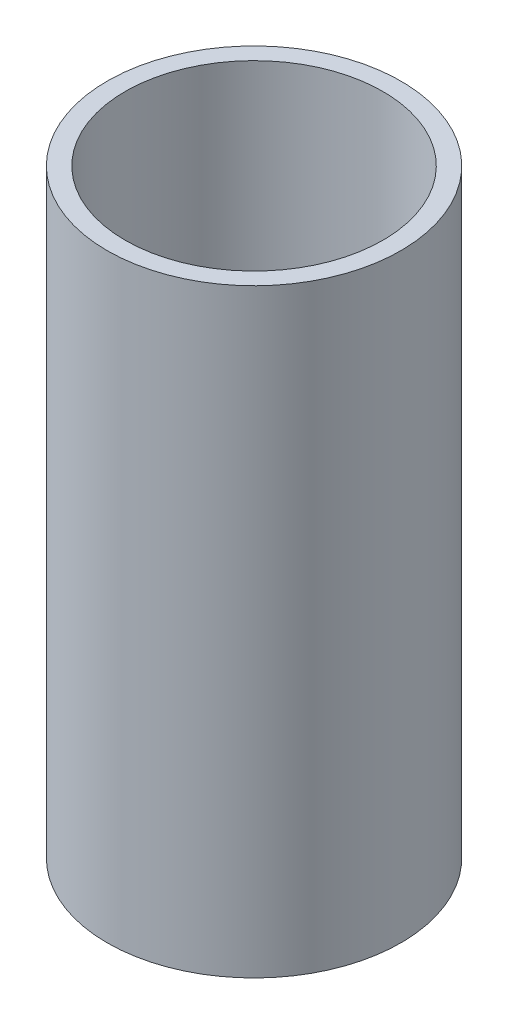
from build123d import *

# Parameters (mm, degrees)
SKETCH1_R           = 4.9
BOSS_EXTRUDE1_DEPTH = 20
SKETCH2_R           = 4.3
CUT_EXTRUDE1_DEPTH  = 19.5


with BuildPart() as part:
    # Sketch1 → Boss-Extrude1 (new body)
    with BuildSketch(Plane(origin=(0, 0, 0), x_dir=(1, 0, 0), z_dir=(0, 1, 0))):
        Circle(SKETCH1_R)
    extrude(amount=-BOSS_EXTRUDE1_DEPTH)

    # Sketch2 → Cut-Extrude1 (cut)
    with BuildSketch(Plane(origin=(0, 0, 0), x_dir=(1, 0, 0), z_dir=(0, 1, 0))):
        Circle(SKETCH2_R)
    extrude(amount=-CUT_EXTRUDE1_DEPTH, mode=Mode.SUBTRACT)


solid = part.part
